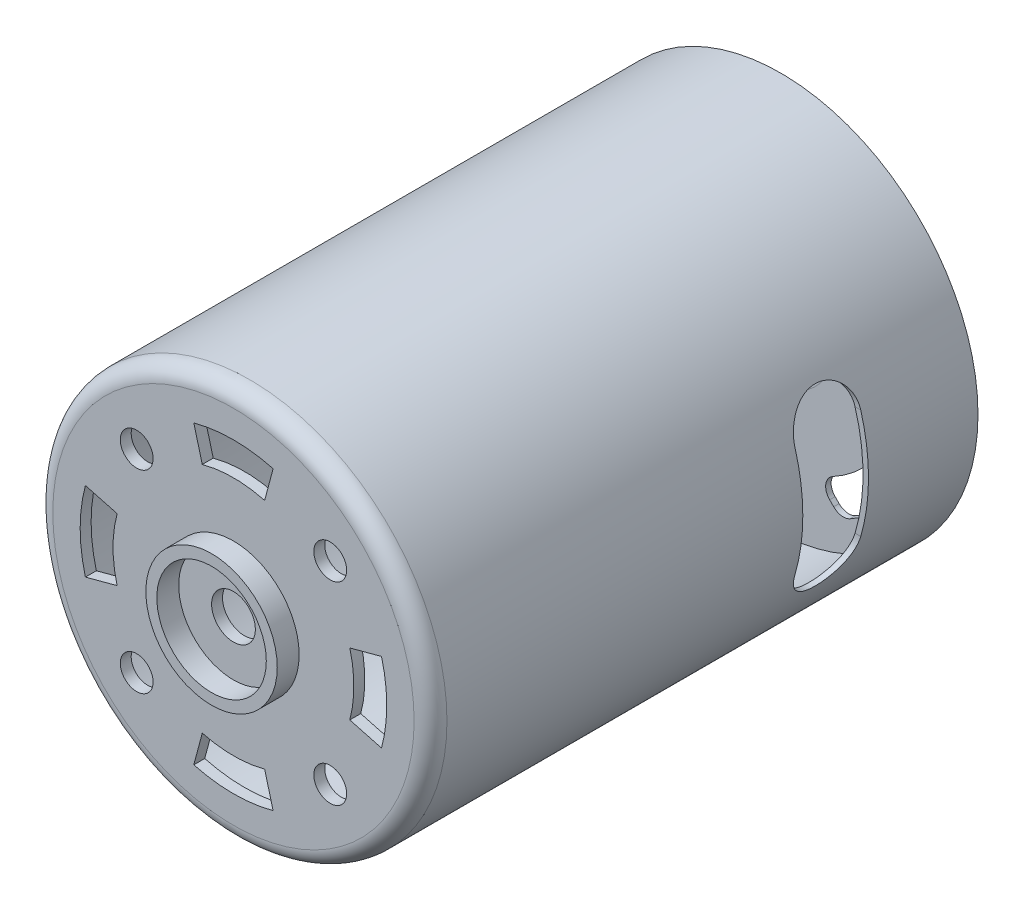
from build123d import *

# Parameters (mm, degrees)
CROQUIS1_R              = 18
CROQUIS1_R_2            = 17.5
SALIENTE_EXTRUIR1_DEPTH = 50
CROQUIS2_R              = 17.5
SALIENTE_EXTRUIR2_DEPTH = 1
CORTAR_EXTRUIR1_DEPTH   = 19
REDONDEO1_R             = 1.5
SKETCH1_R               = 2
CUT_EXTRUDE1_DEPTH      = 10
CUT_EXTRUDE2_DEPTH      = 10
CUT_EXTRUDE3_DEPTH      = 0.5
BOSS_EXTRUDE1_DEPTH     = 0.5
BOSS_EXTRUDE1_2_DEPTH   = 0.5
BOSS_EXTRUDE1_3_DEPTH   = 0.5
BOSS_EXTRUDE1_4_DEPTH   = 0.5
BOSS_EXTRUDE1_5_DEPTH   = 0.5
BOSS_EXTRUDE1_6_DEPTH   = 0.5
BOSS_EXTRUDE5_DEPTH     = 0.1
BOSS_EXTRUDE5_2_DEPTH   = 0.1
BOSS_EXTRUDE5_3_DEPTH   = 0.1
BOSS_EXTRUDE5_4_DEPTH   = 0.1
BOSS_EXTRUDE5_5_DEPTH   = 0.1
BOSS_EXTRUDE5_6_DEPTH   = 0.1
SKETCH8_W               = 1.5
SKETCH8_H               = 4
CUT_EXTRUDE4_DEPTH      = 10
SKETCH9_R               = 1.5
CUT_EXTRUDE5_DEPTH      = 10
SKETCH10_R              = 6
SKETCH10_R_2            = 5
BOSS_EXTRUDE6_DEPTH     = 2


with BuildPart() as part:
    # Croquis1 → Saliente-Extruir1 (new body)
    with BuildSketch(Plane.XY):
        Circle(CROQUIS1_R)
        Circle(CROQUIS1_R_2, mode=Mode.SUBTRACT)
    extrude(amount=SALIENTE_EXTRUIR1_DEPTH)

    # Croquis2 → Saliente-Extruir2 (add)
    with BuildSketch(Plane.XY.offset(50)):
        Circle(CROQUIS2_R)
    extrude(amount=-SALIENTE_EXTRUIR2_DEPTH)

    # Croquis5 → Cortar-Extruir1 (cut, symmetric)
    with BuildSketch(Plane(origin=(0, 0, 0), x_dir=(0, 0, -1), z_dir=(1, 0, 0))):
        with BuildLine():
            Line((-10, 5), (-10, -5))
            ThreePointArc((-10, -5), (-13, -8), (-16, -5))
            Line((-16, -5), (-16, 5))
            ThreePointArc((-16, 5), (-13, 8), (-10, 5))
        make_face()
    extrude(amount=CORTAR_EXTRUIR1_DEPTH, both=True, mode=Mode.SUBTRACT)

    # Redondeo1
    redondeo1_edges = [part.edges().sort_by_distance(p)[0] for p in [
        (-17.5, 0, 49),
        (-18, 0, 50),
    ]]
    fillet(redondeo1_edges, radius=REDONDEO1_R)

    # Sketch1 → Cut-Extrude1 (cut)
    with BuildSketch(Plane.XY.offset(50)):
        Circle(SKETCH1_R)
    extrude(amount=-CUT_EXTRUDE1_DEPTH, mode=Mode.SUBTRACT)

    # Sketch2 → Revolve1 (revolve)
    with BuildSketch(Plane(origin=(0, 0, 0), x_dir=(0, 0, -1), z_dir=(1, 0, 0))):
        with BuildLine():
            Line((-0.5, -2), (-0.5, -3.930100413))
            ThreePointArc((-0.5, -3.930100413), (-0.541526972, -4.335542637), (-0.664383398, -4.724148074))
            Line((-0.664383398, -4.724148074), (-0.835616602, -5.119991459))
            ThreePointArc((-0.835616602, -5.119991459), (-0.958473028, -5.508596895), (-1, -5.91403912))
            Line((-1, -5.91403912), (-1, -17.5))
            Line((-1, -17.5), (-0.5, -17.5))
            Line((-0.5, -17.5), (-0.5, -6.01755184))
            ThreePointArc((-0.5, -6.01755184), (-0.458473326, -5.612108115), (-0.335616602, -5.223501239))
            Line((-0.335616602, -5.223501239), (-0.164383398, -4.827657854))
            ThreePointArc((-0.164383398, -4.827657854), (-0.041526729, -4.439051245), (0, -4.033607798))
            Line((0, -4.033607798), (0, -2))
            Line((0, -2), (-0.5, -2))
        make_face()
    revolve(axis=Axis((0, 0, 0), (0, 0, 1)))

    # Sketch3 → Cut-Extrude2 (cut)
    with BuildSketch(Plane(origin=(0, 0, 0.5), x_dir=(-1, 0, 0), z_dir=(0, 0, -1))):
        with BuildLine():
            Line((-12.521634284, 5.450566472), (-12.889677373, 5.818609561))
            ThreePointArc((-12.889677373, 5.818609561), (-13.243890781, 6.530399735), (-13.097229705, 7.311810586))
            ThreePointArc((-13.097229705, 7.311810586), (-10.606601718, 10.606601718), (-7.311810586, 13.097229705))
            ThreePointArc((-7.311810586, 13.097229705), (-6.530399735, 13.243890781), (-5.818609561, 12.889677373))
            Line((-5.818609561, 12.889677373), (-5.450566472, 12.521634284))
            ThreePointArc((-5.450566472, 12.521634284), (-5.097292691, 11.45902778), (-5.736860331, 10.539849788))
            ThreePointArc((-5.736860331, 10.539849788), (-8.485281374, 8.485281374), (-10.539849788, 5.736860331))
            ThreePointArc((-10.539849788, 5.736860331), (-11.45902778, 5.097292691), (-12.521634284, 5.450566472))
        make_face()
        with BuildLine():
            Line((-5.450566472, -12.521634284), (-5.818609561, -12.889677373))
            ThreePointArc((-5.818609561, -12.889677373), (-6.530399735, -13.243890781), (-7.311810586, -13.097229705))
            ThreePointArc((-7.311810586, -13.097229705), (-10.606601718, -10.606601718), (-13.097229705, -7.311810586))
            ThreePointArc((-13.097229705, -7.311810586), (-13.243890781, -6.530399735), (-12.889677373, -5.818609561))
            Line((-12.889677373, -5.818609561), (-12.521634284, -5.450566472))
            ThreePointArc((-12.521634284, -5.450566472), (-11.45902778, -5.097292691), (-10.539849788, -5.736860331))
            ThreePointArc((-10.539849788, -5.736860331), (-8.485281374, -8.485281374), (-5.736860331, -10.539849788))
            ThreePointArc((-5.736860331, -10.539849788), (-5.097292691, -11.45902778), (-5.450566472, -12.521634284))
        make_face()
        with BuildLine():
            Line((5.450566472, 12.521634284), (5.818609561, 12.889677373))
            ThreePointArc((5.818609561, 12.889677373), (6.530399735, 13.243890781), (7.311810586, 13.097229705))
            ThreePointArc((7.311810586, 13.097229705), (10.606601718, 10.606601718), (13.097229705, 7.311810586))
            ThreePointArc((13.097229705, 7.311810586), (13.243890781, 6.530399735), (12.889677373, 5.818609561))
            Line((12.889677373, 5.818609561), (12.521634284, 5.450566472))
            ThreePointArc((12.521634284, 5.450566472), (11.45902778, 5.097292691), (10.539849788, 5.736860331))
            ThreePointArc((10.539849788, 5.736860331), (8.485281374, 8.485281374), (5.736860331, 10.539849788))
            ThreePointArc((5.736860331, 10.539849788), (5.097292691, 11.45902778), (5.450566472, 12.521634284))
        make_face()
        with BuildLine():
            Line((12.521634284, -5.450566472), (12.889677373, -5.818609561))
            ThreePointArc((12.889677373, -5.818609561), (13.243890781, -6.530399735), (13.097229705, -7.311810586))
            ThreePointArc((13.097229705, -7.311810586), (10.606601718, -10.606601718), (7.311810586, -13.097229705))
            ThreePointArc((7.311810586, -13.097229705), (6.530399735, -13.243890781), (5.818609561, -12.889677373))
            Line((5.818609561, -12.889677373), (5.450566472, -12.521634284))
            ThreePointArc((5.450566472, -12.521634284), (5.097292691, -11.45902778), (5.736860331, -10.539849788))
            ThreePointArc((5.736860331, -10.539849788), (8.485281374, -8.485281374), (10.539849788, -5.736860331))
            ThreePointArc((10.539849788, -5.736860331), (11.45902778, -5.097292691), (12.521634284, -5.450566472))
        make_face()
    extrude(amount=-CUT_EXTRUDE2_DEPTH, mode=Mode.SUBTRACT)

    # Sketch4 → Cut-Extrude3 (cut)
    with BuildSketch(Plane(origin=(0, 0, 0), x_dir=(-1, 0, 0), z_dir=(0, 0, -1))):
        with BuildLine():
            Line((1.5, -17.435595774), (1.5, -17.686506156))
            ThreePointArc((1.5, -17.686506156), (0, -17.75), (-1.5, -17.686506156))
            Line((-1.5, -17.686506156), (-1.5, -17.435595774))
            ThreePointArc((-1.5, -17.435595774), (0, -17.5), (1.5, -17.435595774))
        make_face()
        with BuildLine():
            Line((-14.349668871, -10.016835993), (-14.566963635, -10.142291184))
            ThreePointArc((-14.566963635, -10.142291184), (-15.371950917, -8.875), (-16.066963635, -7.544214972))
            Line((-16.066963635, -7.544214972), (-15.849668871, -7.418759781))
            ThreePointArc((-15.849668871, -7.418759781), (-15.155444566, -8.75), (-14.349668871, -10.016835993))
        make_face()
        with BuildLine():
            Line((-15.849668871, 7.418759781), (-16.066963635, 7.544214972))
            ThreePointArc((-16.066963635, 7.544214972), (-15.371950917, 8.875), (-14.566963635, 10.142291184))
            Line((-14.566963635, 10.142291184), (-14.349668871, 10.016835993))
            ThreePointArc((-14.349668871, 10.016835993), (-15.155444566, 8.75), (-15.849668871, 7.418759781))
        make_face()
        with BuildLine():
            Line((-1.5, 17.435595774), (-1.5, 17.686506156))
            ThreePointArc((-1.5, 17.686506156), (0, 17.75), (1.5, 17.686506156))
            Line((1.5, 17.686506156), (1.5, 17.435595774))
            ThreePointArc((1.5, 17.435595774), (0, 17.5), (-1.5, 17.435595774))
        make_face()
        with BuildLine():
            Line((14.349668871, 10.016835993), (14.566963635, 10.142291184))
            ThreePointArc((14.566963635, 10.142291184), (15.371950917, 8.875), (16.066963635, 7.544214972))
            Line((16.066963635, 7.544214972), (15.849668871, 7.418759781))
            ThreePointArc((15.849668871, 7.418759781), (15.155444566, 8.75), (14.349668871, 10.016835993))
        make_face()
        with BuildLine():
            Line((15.849668871, -7.418759781), (16.066963635, -7.544214972))
            ThreePointArc((16.066963635, -7.544214972), (15.371950917, -8.875), (14.566963635, -10.142291184))
            Line((14.566963635, -10.142291184), (14.349668871, -10.016835993))
            ThreePointArc((14.349668871, -10.016835993), (15.155444566, -8.75), (15.849668871, -7.418759781))
        make_face()
    extrude(amount=-CUT_EXTRUDE3_DEPTH, mode=Mode.SUBTRACT)

    # Sketch8 → Cut-Extrude4 (cut)
    with BuildSketch(Plane(origin=(0, 0, 0.5), x_dir=(-1, 0, 0), z_dir=(0, 0, -1))):
        with Locations((-12, 0)):
            Rectangle(SKETCH8_W, SKETCH8_H)
        with Locations((12, 0)):
            Rectangle(SKETCH8_W, SKETCH8_H)
    extrude(amount=-CUT_EXTRUDE4_DEPTH, mode=Mode.SUBTRACT)

    # Sketch9 → Cut-Extrude5 (cut)
    with BuildSketch(Plane.XY.offset(50)):
        with Locations((8.838834765, 8.838834765)):
            Circle(SKETCH9_R)
        with Locations((8.838834765, -8.838834765)):
            Circle(SKETCH9_R)
        with Locations((-8.838834765, -8.838834765)):
            Circle(SKETCH9_R)
        with Locations((-8.838834765, 8.838834765)):
            Circle(SKETCH9_R)
        with BuildLine():
            Line((-2.847009496, 10.625184089), (-3.623466631, 13.522961568))
            ThreePointArc((-3.623466631, 13.522961568), (0, 14), (3.623466631, 13.522961568))
            Line((3.623466631, 13.522961568), (2.847009496, 10.625184089))
            ThreePointArc((2.847009496, 10.625184089), (0, 11), (-2.847009496, 10.625184089))
        make_face()
        with BuildLine():
            Line((10.625184089, 2.847009496), (13.522961568, 3.623466631))
            ThreePointArc((13.522961568, 3.623466631), (14, 0), (13.522961568, -3.623466631))
            Line((13.522961568, -3.623466631), (10.625184089, -2.847009496))
            ThreePointArc((10.625184089, -2.847009496), (11, 0), (10.625184089, 2.847009496))
        make_face()
        with BuildLine():
            Line((2.847009496, -10.625184089), (3.623466631, -13.522961568))
            ThreePointArc((3.623466631, -13.522961568), (0, -14), (-3.623466631, -13.522961568))
            Line((-3.623466631, -13.522961568), (-2.847009496, -10.625184089))
            ThreePointArc((-2.847009496, -10.625184089), (0, -11), (2.847009496, -10.625184089))
        make_face()
        with BuildLine():
            Line((-10.625184089, -2.847009496), (-13.522961568, -3.623466631))
            ThreePointArc((-13.522961568, -3.623466631), (-14, 0), (-13.522961568, 3.623466631))
            Line((-13.522961568, 3.623466631), (-10.625184089, 2.847009496))
            ThreePointArc((-10.625184089, 2.847009496), (-11, 0), (-10.625184089, -2.847009496))
        make_face()
    extrude(amount=-CUT_EXTRUDE5_DEPTH, mode=Mode.SUBTRACT)

    # Sketch10 → Boss-Extrude6 (add)
    with BuildSketch(Plane.XY.offset(50)):
        Circle(SKETCH10_R)
        Circle(SKETCH10_R_2, mode=Mode.SUBTRACT)
    extrude(amount=BOSS_EXTRUDE6_DEPTH)


with BuildPart() as body_2:
    # Sketch5 → Boss-Extrude1 (new body)
    with BuildSketch(Plane(origin=(0, 0, 0.5), x_dir=(-1, 0, 0), z_dir=(0, 0, -1))):
        with BuildLine():
            Line((1.5, -17.686506156), (1.5, -17.435595774))
            ThreePointArc((1.5, -17.435595774), (0, -17.5), (-1.5, -17.435595774))
            Line((-1.5, -17.435595774), (-1.5, -17.686506156))
            ThreePointArc((-1.5, -17.686506156), (0, -17.75), (1.5, -17.686506156))
        make_face()
    extrude(amount=BOSS_EXTRUDE1_DEPTH)


with BuildPart() as body_3:
    # Sketch5 → Boss-Extrude1 2 (new body)
    with BuildSketch(Plane(origin=(0, 0, 0.5), x_dir=(-1, 0, 0), z_dir=(0, 0, -1))):
        with BuildLine():
            Line((-14.566963635, -10.142291184), (-14.349668871, -10.016835993))
            ThreePointArc((-14.349668871, -10.016835993), (-15.155444566, -8.75), (-15.849668871, -7.418759781))
            Line((-15.849668871, -7.418759781), (-16.066963635, -7.544214972))
            ThreePointArc((-16.066963635, -7.544214972), (-15.371950917, -8.875), (-14.566963635, -10.142291184))
        make_face()
    extrude(amount=BOSS_EXTRUDE1_2_DEPTH)


with BuildPart() as body_4:
    # Sketch5 → Boss-Extrude1 3 (new body)
    with BuildSketch(Plane(origin=(0, 0, 0.5), x_dir=(-1, 0, 0), z_dir=(0, 0, -1))):
        with BuildLine():
            Line((-16.066963635, 7.544214972), (-15.849668871, 7.418759781))
            ThreePointArc((-15.849668871, 7.418759781), (-15.155444566, 8.75), (-14.349668871, 10.016835993))
            Line((-14.349668871, 10.016835993), (-14.566963635, 10.142291184))
            ThreePointArc((-14.566963635, 10.142291184), (-15.371950917, 8.875), (-16.066963635, 7.544214972))
        make_face()
    extrude(amount=BOSS_EXTRUDE1_3_DEPTH)


with BuildPart() as body_5:
    # Sketch5 → Boss-Extrude1 4 (new body)
    with BuildSketch(Plane(origin=(0, 0, 0.5), x_dir=(-1, 0, 0), z_dir=(0, 0, -1))):
        with BuildLine():
            Line((-1.5, 17.686506156), (-1.5, 17.435595774))
            ThreePointArc((-1.5, 17.435595774), (0, 17.5), (1.5, 17.435595774))
            Line((1.5, 17.435595774), (1.5, 17.686506156))
            ThreePointArc((1.5, 17.686506156), (0, 17.75), (-1.5, 17.686506156))
        make_face()
    extrude(amount=BOSS_EXTRUDE1_4_DEPTH)


with BuildPart() as body_6:
    # Sketch5 → Boss-Extrude1 5 (new body)
    with BuildSketch(Plane(origin=(0, 0, 0.5), x_dir=(-1, 0, 0), z_dir=(0, 0, -1))):
        with BuildLine():
            Line((14.566963635, 10.142291184), (14.349668871, 10.016835993))
            ThreePointArc((14.349668871, 10.016835993), (15.155444566, 8.75), (15.849668871, 7.418759781))
            Line((15.849668871, 7.418759781), (16.066963635, 7.544214972))
            ThreePointArc((16.066963635, 7.544214972), (15.371950917, 8.875), (14.566963635, 10.142291184))
        make_face()
    extrude(amount=BOSS_EXTRUDE1_5_DEPTH)


with BuildPart() as body_7:
    # Sketch5 → Boss-Extrude1 6 (new body)
    with BuildSketch(Plane(origin=(0, 0, 0.5), x_dir=(-1, 0, 0), z_dir=(0, 0, -1))):
        with BuildLine():
            Line((16.066963635, -7.544214972), (15.849668871, -7.418759781))
            ThreePointArc((15.849668871, -7.418759781), (15.155444566, -8.75), (14.349668871, -10.016835993))
            Line((14.349668871, -10.016835993), (14.566963635, -10.142291184))
            ThreePointArc((14.566963635, -10.142291184), (15.371950917, -8.875), (16.066963635, -7.544214972))
        make_face()
    extrude(amount=BOSS_EXTRUDE1_6_DEPTH)


with BuildPart() as body_8:
    # Sketch7 → Boss-Extrude5 (new body)
    with BuildSketch(Plane(origin=(0, 0, 0.5), x_dir=(-1, 0, 0), z_dir=(0, 0, -1))):
        with BuildLine():
            Line((-1.5, -17.435595774), (-1.5, -16.685595774))
            ThreePointArc((-1.5, -16.685595774), (0, -15.400403363), (1.5, -16.685595774))
            Line((1.5, -16.685595774), (1.5, -17.435595774))
            ThreePointArc((1.5, -17.435595774), (0, -17.5), (-1.5, -17.435595774))
        make_face()
    extrude(amount=BOSS_EXTRUDE5_DEPTH)


with BuildPart() as body_9:
    # Sketch7 → Boss-Extrude5 2 (new body)
    with BuildSketch(Plane(origin=(0, 0, 0.5), x_dir=(-1, 0, 0), z_dir=(0, 0, -1))):
        with BuildLine():
            Line((-15.849668871, -7.418759781), (-15.200149818, -7.043759781))
            ThreePointArc((-15.200149818, -7.043759781), (-13.337140541, -7.700201681), (-13.700149818, -9.641835993))
            Line((-13.700149818, -9.641835993), (-14.349668871, -10.016835993))
            ThreePointArc((-14.349668871, -10.016835993), (-15.155444566, -8.75), (-15.849668871, -7.418759781))
        make_face()
    extrude(amount=BOSS_EXTRUDE5_2_DEPTH)


with BuildPart() as body_10:
    # Sketch7 → Boss-Extrude5 3 (new body)
    with BuildSketch(Plane(origin=(0, 0, 0.5), x_dir=(-1, 0, 0), z_dir=(0, 0, -1))):
        with BuildLine():
            Line((-14.349668871, 10.016835993), (-13.700149818, 9.641835993))
            ThreePointArc((-13.700149818, 9.641835993), (-13.337140541, 7.700201681), (-15.200149818, 7.043759781))
            Line((-15.200149818, 7.043759781), (-15.849668871, 7.418759781))
            ThreePointArc((-15.849668871, 7.418759781), (-15.155444566, 8.75), (-14.349668871, 10.016835993))
        make_face()
    extrude(amount=BOSS_EXTRUDE5_3_DEPTH)


with BuildPart() as body_11:
    # Sketch7 → Boss-Extrude5 4 (new body)
    with BuildSketch(Plane(origin=(0, 0, 0.5), x_dir=(-1, 0, 0), z_dir=(0, 0, -1))):
        with BuildLine():
            Line((1.5, 17.435595774), (1.5, 16.685595774))
            ThreePointArc((1.5, 16.685595774), (0, 15.400403363), (-1.5, 16.685595774))
            Line((-1.5, 16.685595774), (-1.5, 17.435595774))
            ThreePointArc((-1.5, 17.435595774), (0, 17.5), (1.5, 17.435595774))
        make_face()
    extrude(amount=BOSS_EXTRUDE5_4_DEPTH)


with BuildPart() as body_12:
    # Sketch7 → Boss-Extrude5 5 (new body)
    with BuildSketch(Plane(origin=(0, 0, 0.5), x_dir=(-1, 0, 0), z_dir=(0, 0, -1))):
        with BuildLine():
            Line((15.849668871, 7.418759781), (15.200149818, 7.043759781))
            ThreePointArc((15.200149818, 7.043759781), (13.337140541, 7.700201681), (13.700149818, 9.641835993))
            Line((13.700149818, 9.641835993), (14.349668871, 10.016835993))
            ThreePointArc((14.349668871, 10.016835993), (15.155444566, 8.75), (15.849668871, 7.418759781))
        make_face()
    extrude(amount=BOSS_EXTRUDE5_5_DEPTH)


with BuildPart() as body_13:
    # Sketch7 → Boss-Extrude5 6 (new body)
    with BuildSketch(Plane(origin=(0, 0, 0.5), x_dir=(-1, 0, 0), z_dir=(0, 0, -1))):
        with BuildLine():
            Line((14.349668871, -10.016835993), (13.700149818, -9.641835993))
            ThreePointArc((13.700149818, -9.641835993), (13.337140541, -7.700201681), (15.200149818, -7.043759781))
            Line((15.200149818, -7.043759781), (15.849668871, -7.418759781))
            ThreePointArc((15.849668871, -7.418759781), (15.155444566, -8.75), (14.349668871, -10.016835993))
        make_face()
    extrude(amount=BOSS_EXTRUDE5_6_DEPTH)


solid = Compound([part.part, body_2.part, body_3.part, body_4.part, body_5.part, body_6.part, body_7.part, body_8.part, body_9.part, body_10.part, body_11.part, body_12.part, body_13.part])
